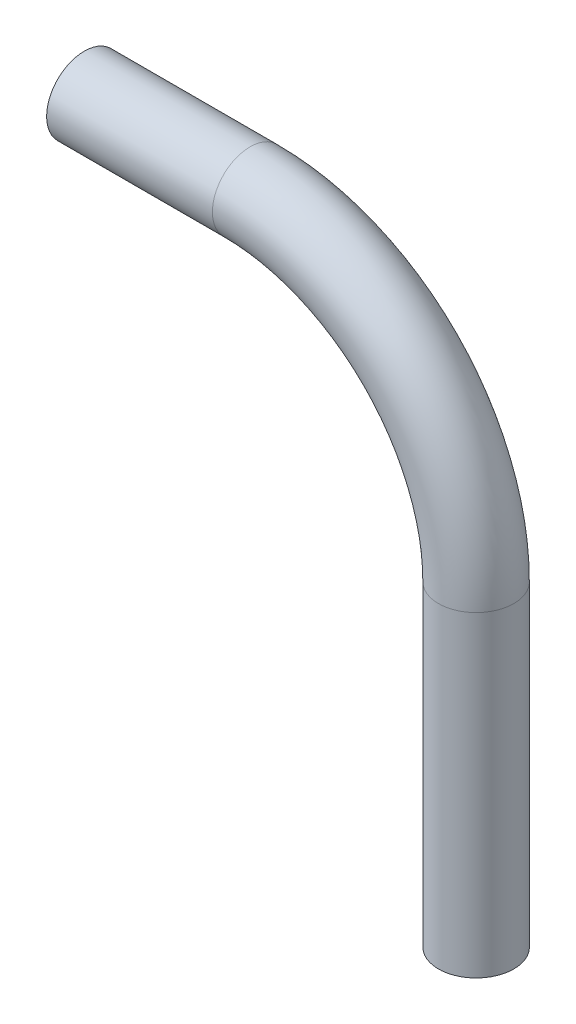
from build123d import *

# Parameters (mm, degrees)
SKETCH2_R   = 3.175
SKETCH2_R_2 = 1.524


with BuildPart() as part:
    # Sweep1: sweep along a path in Sketch1
    with BuildLine(Plane.XY) as sweep1_path:
        Line((35.311373379, 20.962704245), (49.281373379, 20.962704245))
        ThreePointArc((49.281373379, 20.962704245), (62.751757561, 15.383088426), (68.331373379, 1.912704245))
        Line((68.331373379, 1.912704245), (68.331373379, -24.757295755))
    # Sketch2 → Sweep1 (sweep)
    with BuildSketch(Plane(origin=(35.311373379, 20.962704245, 0), x_dir=(0, 0, -1), z_dir=(1, 0, 0))):
        Circle(SKETCH2_R)
        Circle(SKETCH2_R_2, mode=Mode.SUBTRACT)
    sweep(path=sweep1_path.line)


solid = part.part
